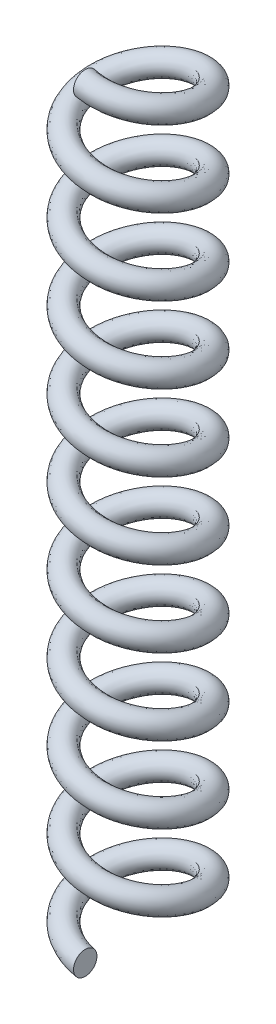
from build123d import *

# Parameters (mm, degrees)
SWEEP_1_PITCH  = 6.5
SWEEP_1_HEIGHT = 65
SWEEP_1_RADIUS = 4.5
SKETCH_2_R     = 1


with BuildPart() as part:
    # 扫描1: sweep along a helix
    with BuildLine() as sweep_1_path:
        Helix(SWEEP_1_PITCH, SWEEP_1_HEIGHT, SWEEP_1_RADIUS, center=(0, 0, 0), direction=(0, 1, 0), lefthand=True)
    # 草图2 → 扫描1 (sweep)
    with BuildSketch(Plane(origin=(0, 0, 0), x_dir=(0, 0, -1), z_dir=(1, 0, 0))):
        with Locations((-4.5, 0)):
            Circle(SKETCH_2_R)
    sweep(path=sweep_1_path.line, is_frenet=True)


solid = part.part
